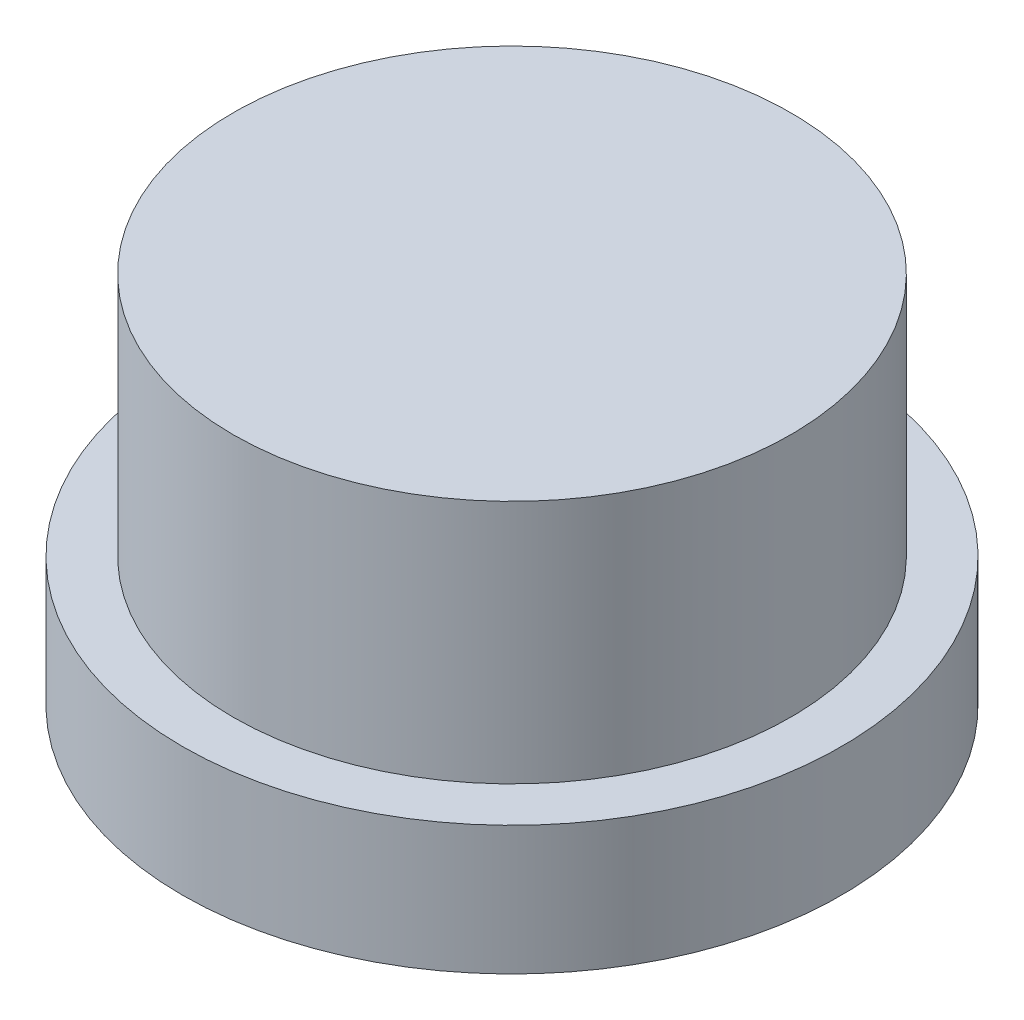
from build123d import *

# Parameters (mm, degrees)
SKETCH1_R           = 6.5
BOSS_EXTRUDE1_DEPTH = 2.54
SKETCH2_R           = 5.5
BOSS_EXTRUDE2_DEPTH = 4.826


with BuildPart() as part:
    # Sketch1 → Boss-Extrude1 (new body)
    with BuildSketch(Plane(origin=(0, 0, 0), x_dir=(1, 0, 0), z_dir=(0, 1, 0))):
        Circle(SKETCH1_R)
    extrude(amount=BOSS_EXTRUDE1_DEPTH)

    # Sketch2 → Boss-Extrude2 (add)
    with BuildSketch(Plane(origin=(0, 2.54, 0), x_dir=(1, 0, 0), z_dir=(0, 1, 0))):
        Circle(SKETCH2_R)
    extrude(amount=BOSS_EXTRUDE2_DEPTH)


solid = part.part
